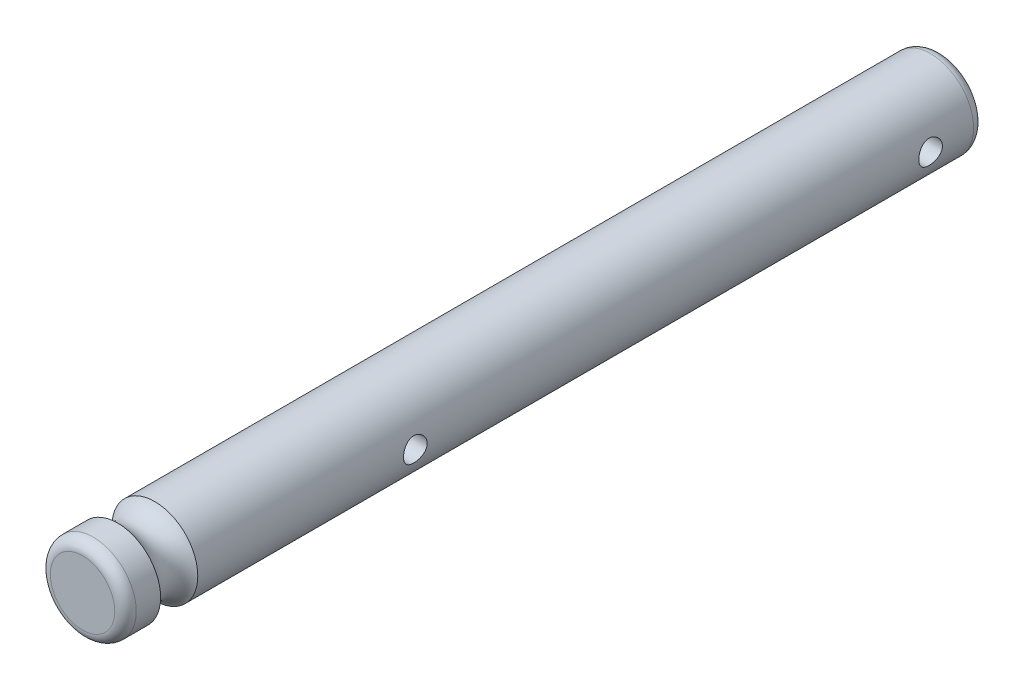
from build123d import *

# Parameters (mm, degrees)
SKETCH1_R               = 2
BOSS_EXTRUDE1_DEPTH     = 35
SKETCH2_R               = 2
BOSS_EXTRUDE2_DEPTH     = 5
SKETCH3_R               = 1
FILLET1_R               = 0.5
SKETCH4_R               = 0.55
CUT_EXTRUDE1_DEPTH      = 30.858564979
CUT_EXTRUDE1_DEPTH_BACK = 1


with BuildPart() as part:
    # Sketch1 → Boss-Extrude1 (new body)
    with BuildSketch(Plane.XY):
        with Locations((27.858564979, 100.826239149)):
            Circle(SKETCH1_R)
    extrude(amount=-BOSS_EXTRUDE1_DEPTH)

    # Sketch2 → Boss-Extrude2 (add)
    with BuildSketch(Plane.XY):
        with Locations((27.858564979, 100.826239149)):
            Circle(SKETCH2_R)
    extrude(amount=BOSS_EXTRUDE2_DEPTH)

    # Sketch3 → Cut-Revolve1 (revolve, cut)
    with BuildSketch(Plane(origin=(27.858564979, 0, 0), x_dir=(0, 0, -1), z_dir=(1, 0, 0))):
        with Locations((-2.5, 103.326239149)):
            Circle(SKETCH3_R)
    revolve(axis=Axis((27.858564979, 100.826239149, -35), (0, 0, 1)), mode=Mode.SUBTRACT)

    # Fillet1
    fillet1_edges = [part.edges().sort_by_distance(p)[0] for p in [
        (25.858564979, 100.826239149, -35),
        (25.858564979, 100.826239149, 5),
    ]]
    fillet(fillet1_edges, radius=FILLET1_R)

    # Sketch4 → Cut-Extrude1 (cut, two sides)
    with BuildSketch(Plane(origin=(0, 0, 0), x_dir=(0, 0, -1), z_dir=(1, 0, 0))) as cut_extrude1_sk:
        with Locations((32.5, 100.826239149)):
            Circle(SKETCH4_R)
        with Locations((8.5, 100.826239149)):
            Circle(SKETCH4_R)
    extrude(amount=CUT_EXTRUDE1_DEPTH, mode=Mode.SUBTRACT)
    extrude(cut_extrude1_sk.sketch, amount=-CUT_EXTRUDE1_DEPTH_BACK, mode=Mode.SUBTRACT)


solid = part.part
